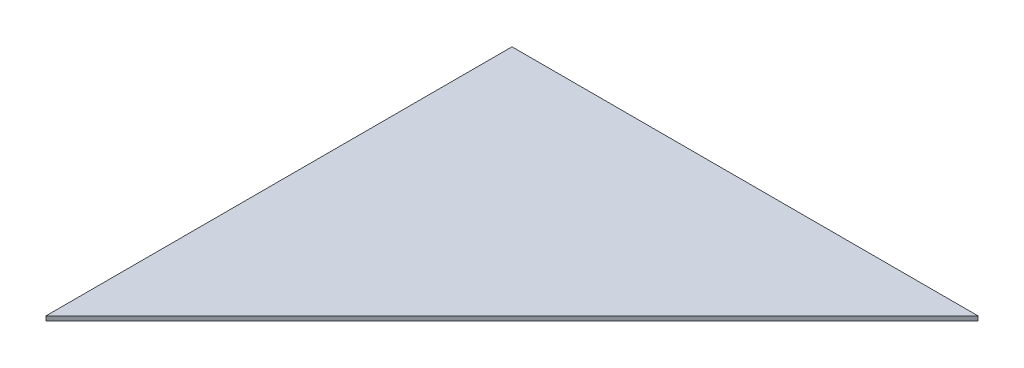
from build123d import *

# Parameters (mm, degrees)
SKETCH1_W           = 1219.2
SKETCH1_H           = 1219.2
BOSS_EXTRUDE1_DEPTH = 5.55625
CUT_EXTRUDE1_DEPTH  = 6.55625


with BuildPart() as part:
    # Sketch1 → Boss-Extrude1 (new body)
    with BuildSketch(Plane(origin=(0, 0, 0), x_dir=(1, 0, 0), z_dir=(0, 1, 0))):
        Rectangle(SKETCH1_W, SKETCH1_H)
    extrude(amount=BOSS_EXTRUDE1_DEPTH)

    # Sketch2 → Cut-Extrude1 (cut, through all)
    with BuildSketch(Plane.XZ):
        Polygon((-609.6, -52.824120495), (-52.824120495, -609.6), (609.6, -609.6), (609.6, 609.6), (-609.6, 609.6), align=None)
    extrude(amount=-CUT_EXTRUDE1_DEPTH, mode=Mode.SUBTRACT)


solid = part.part
